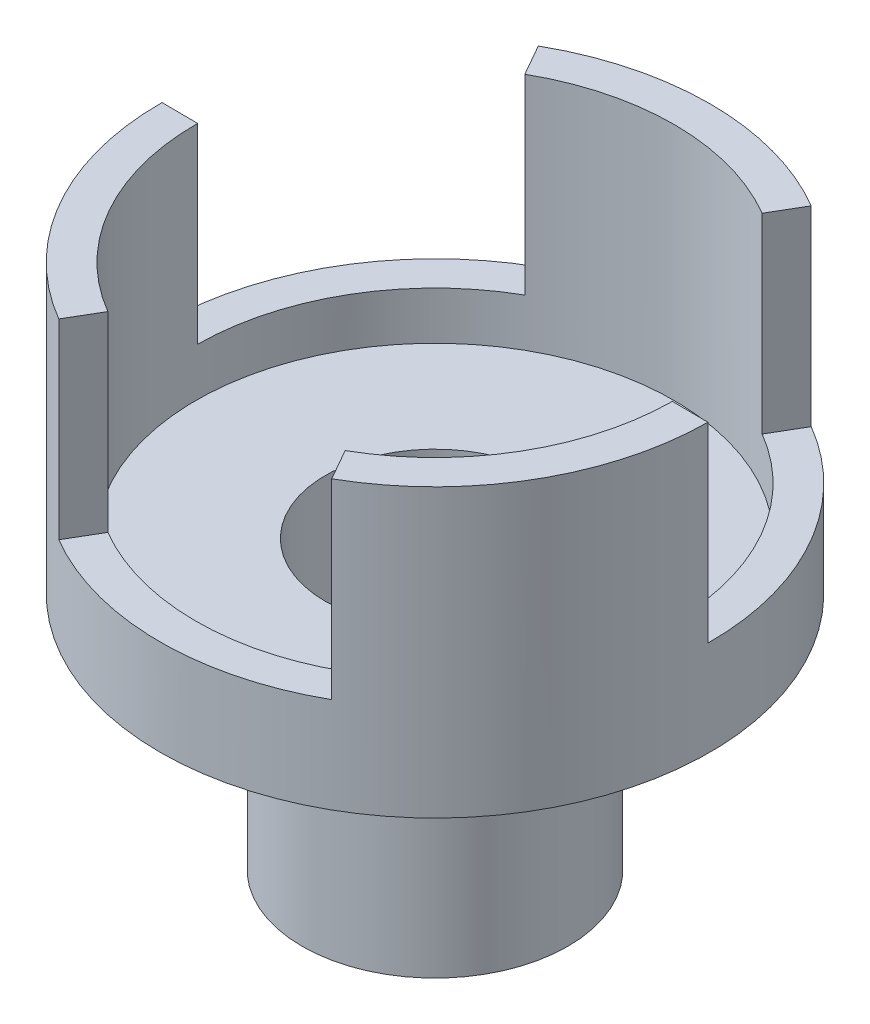
from build123d import *

# Parameters (mm, degrees)
SKETCH1_R           = 11.5
SKETCH1_R_2         = 10
BOSS_EXTRUDE1_DEPTH = 10
BOSS_EXTRUDE3_START = 2
SKETCH2_R           = 11.5
SKETCH2_R_2         = 5.558376586
BOSS_EXTRUDE3_DEPTH = 2
BOSS_EXTRUDE4_START = 10
SKETCH2_3_R         = 5.558376586
SKETCH2_3_R_2       = 4.575743436
BOSS_EXTRUDE4_DEPTH = 10
BOSS_EXTRUDE5_START = 2
SKETCH3_R           = 5.558376586
BOSS_EXTRUDE5_DEPTH = 2
CUT_EXTRUDE1_START  = -8
CUT_EXTRUDE1_DEPTH  = 8


with BuildPart() as part:
    # Sketch1 → Boss-Extrude1 (new body)
    with BuildSketch(Plane(origin=(0, 0, 0), x_dir=(1, 0, 0), z_dir=(0, 1, 0))):
        Circle(SKETCH1_R)
        Circle(SKETCH1_R_2, mode=Mode.SUBTRACT)
    extrude(amount=BOSS_EXTRUDE1_DEPTH)

    # Sketch2 → Boss-Extrude3 (add)
    with BuildSketch(Plane.XZ.offset(BOSS_EXTRUDE3_START)):
        Circle(SKETCH2_R)
        Circle(SKETCH2_R_2, mode=Mode.SUBTRACT)
    extrude(amount=-BOSS_EXTRUDE3_DEPTH)

    # Sketch2_3 → Boss-Extrude4 (add)
    with BuildSketch(Plane.XZ.offset(BOSS_EXTRUDE4_START)):
        Circle(SKETCH2_3_R)
        Circle(SKETCH2_3_R_2, mode=Mode.SUBTRACT)
    extrude(amount=-BOSS_EXTRUDE4_DEPTH)

    # Sketch3 → Boss-Extrude5 (add)
    with BuildSketch(Plane.XZ.offset(10).offset(BOSS_EXTRUDE5_START)):
        Circle(SKETCH3_R)
    extrude(amount=-BOSS_EXTRUDE5_DEPTH)

    # Sketch4 → Cut-Extrude1 (cut)
    with BuildSketch(Plane(origin=(0, 10, 0), x_dir=(1, 0, 0), z_dir=(0, 1, 0)).offset(CUT_EXTRUDE1_START)):
        with BuildLine():
            Line((-5.820799865, -9.918078893), (-5.0615651, -8.624416429))
            ThreePointArc((-5.0615651, -8.624416429), (-0.071235745, -9.99974627), (4.93818117, -8.695652174))
            Line((4.93818117, -8.695652174), (5.678908346, -10))
            ThreePointArc((5.678908346, -10), (-0.081921107, -11.499708211), (-5.820799865, -9.918078893))
        make_face()
        with BuildLine():
            Line((-5.678908346, 10), (-4.93818117, 8.695652174))
            ThreePointArc((-4.93818117, 8.695652174), (-8.624416429, 5.0615651), (-9.99974627, 0.071235745))
            Line((-9.99974627, 0.071235745), (-11.499708211, 0.081921107))
            ThreePointArc((-11.499708211, 0.081921107), (-9.918078893, 5.820799865), (-5.678908346, 10))
        make_face()
        with BuildLine():
            Line((11.499708211, -0.081921107), (9.99974627, -0.071235745))
            ThreePointArc((9.99974627, -0.071235745), (8.695652174, 4.93818117), (5.0615651, 8.624416429))
            Line((5.0615651, 8.624416429), (5.820799865, 9.918078893))
            ThreePointArc((5.820799865, 9.918078893), (10, 5.678908346), (11.499708211, -0.081921107))
        make_face()
    extrude(amount=CUT_EXTRUDE1_DEPTH, mode=Mode.SUBTRACT)


solid = part.part
